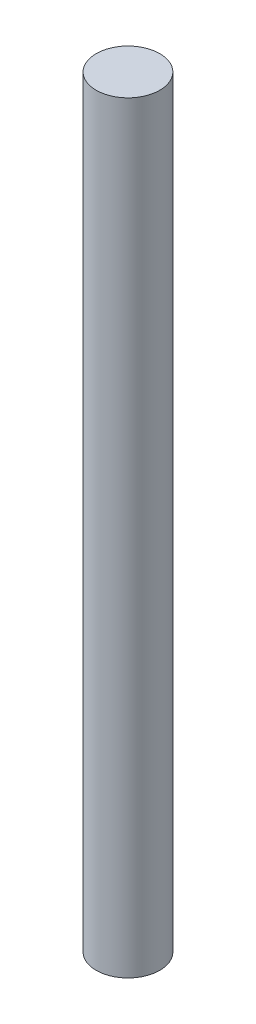
from build123d import *

# Parameters (mm, degrees)
SKETCH1_R           = 1.875
BOSS_EXTRUDE1_DEPTH = 45


with BuildPart() as part:
    # Sketch1 → Boss-Extrude1 (new body)
    with BuildSketch(Plane(origin=(0, 0, 0), x_dir=(1, 0, 0), z_dir=(0, 1, 0))):
        Circle(SKETCH1_R)
    extrude(amount=BOSS_EXTRUDE1_DEPTH)


solid = part.part
